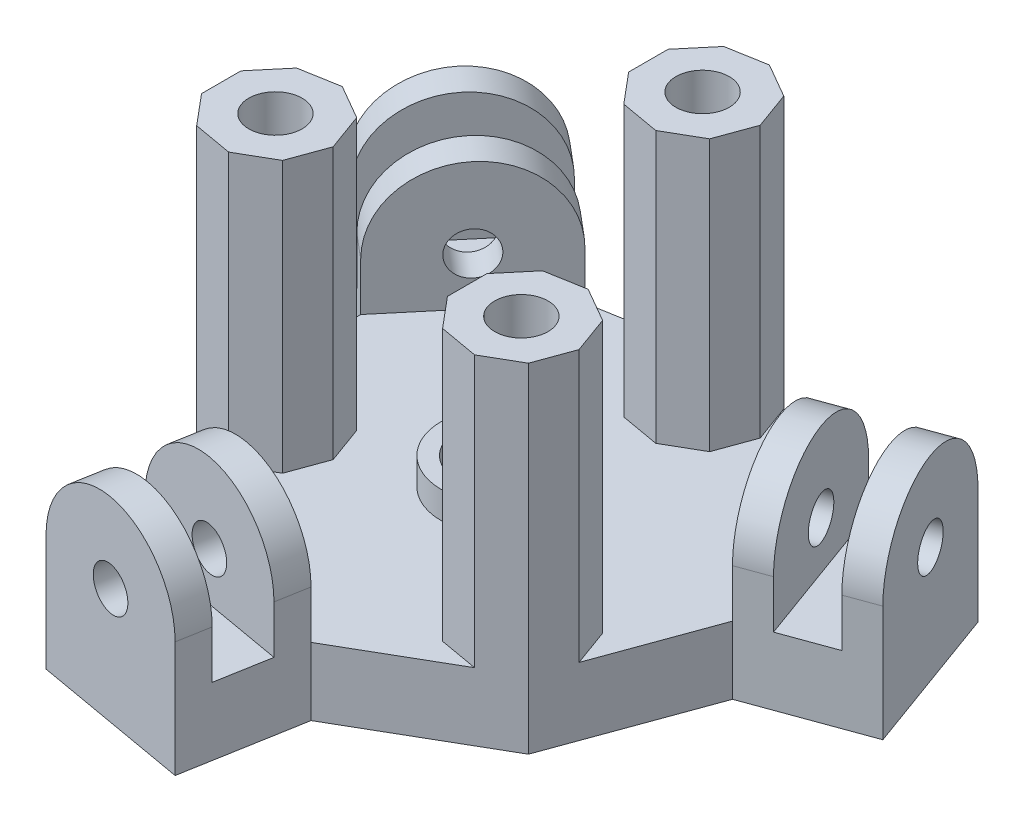
from build123d import *

# Parameters (mm, degrees)
SKETCH1_R            = 4.1
BOSS_EXTRUDE1_DEPTH  = 6.35
SKETCH4_R            = 2
BOSS_EXTRUDE2_DEPTH  = 3
SKETCH6_R            = 1.999996081
BOSS_EXTRUDE4_DEPTH  = 3
SKETCH8_R            = 1.999996
BOSS_EXTRUDE5_DEPTH  = 3
SKETCH9_R            = 1.999996
BOSS_EXTRUDE6_DEPTH  = 3
SKETCH10_R           = 1.999996
BOSS_EXTRUDE7_DEPTH  = 3
SKETCH11_R           = 1.999996
BOSS_EXTRUDE8_DEPTH  = 3
SKETCH12_R           = 2.5
BOSS_EXTRUDE9_DEPTH  = 25.4
SKETCH15_R           = 5.5
SKETCH15_R_2         = 4
BOSS_EXTRUDE10_DEPTH = 2.54


with BuildPart() as part:
    # Sketch1 → Boss-Extrude1 (new body)
    with BuildSketch(Plane(origin=(0, 0, 0), x_dir=(1, 0, 0), z_dir=(0, 1, 0))):
        Polygon((1.878116929, -32.317100962), (-12.817952122, -29.725787478), (-10.907822168, -18.892902195), (3.788246884, -21.484215679), align=None)
        Polygon((-10.907822168, -18.892902195), (3.788246884, -21.484215679), (16.711753116, -14.022825876), (21.815644336, 0), (16.711753116, 14.022825876), (3.788246884, 21.484215679), (-10.907822168, 18.892902195), (-20.5, 7.461389802), (-20.5, -7.461389802), align=None)
        Circle(SKETCH1_R, mode=Mode.SUBTRACT)
        Polygon((27.048371945, 17.785047453), (32.152263164, 3.762221577), (21.815644336, 0), (16.711753116, 14.022825876), align=None)
        Polygon((-28.926488874, 14.532053509), (-19.334311042, 25.963565901), (-10.907822168, 18.892902195), (-20.5, 7.461389802), align=None)
    extrude(amount=BOSS_EXTRUDE1_DEPTH)

    # Sketch4 → Boss-Extrude2 (add)
    with BuildSketch(Plane(origin=(-5.469917597, 0, 31.02144422), x_dir=(-0.984807753, 0, -0.173648178), z_dir=(0.173648178, 0, -0.984807753))):
        with BuildLine():
            Line((-7.461389802, 6.35), (-7.461389802, 10.84999989))
            ThreePointArc((-7.461389802, 10.84999989), (0, 18.311389692), (7.461389802, 10.84999989))
            Line((7.461389802, 10.84999989), (7.461389802, 6.35))
            Line((7.461389802, 6.35), (-7.461389802, 6.35))
        make_face()
        with Locations((0, 10.84999989)):
            Circle(SKETCH4_R, mode=Mode.SUBTRACT)
    extrude(amount=BOSS_EXTRUDE2_DEPTH)

    # Sketch6 → Boss-Extrude4 (add)
    with BuildSketch(Plane(origin=(-3.559787642, 0, 20.188558937), x_dir=(-0.984807753, 0, -0.173648178), z_dir=(0.173648178, 0, -0.984807753))):
        with BuildLine():
            Line((-7.461389802, 6.35), (-7.461389802, 10.85))
            ThreePointArc((-7.461389802, 10.85), (0, 18.311389802), (7.461389802, 10.85))
            Line((7.461389802, 10.85), (7.461389802, 6.35))
            Line((7.461389802, 6.35), (-7.461389802, 6.35))
        make_face()
        with Locations((0, 10.85)):
            Circle(SKETCH6_R, mode=Mode.SUBTRACT)
    extrude(amount=-BOSS_EXTRUDE4_DEPTH)

    # Sketch8 → Boss-Extrude5 (add)
    with BuildSketch(Plane(origin=(29.600317555, 0, -10.773634515), x_dir=(0.342020143, 0, 0.939692621), z_dir=(-0.939692621, 0, 0.342020143))):
        with BuildLine():
            Line((-7.461389802, 10.85), (-7.461389802, 6.35))
            Line((-7.461389802, 6.35), (7.461389802, 6.35))
            Line((7.461389802, 6.35), (7.461389802, 10.85))
            ThreePointArc((7.461389802, 10.85), (0, 18.311389802), (-7.461389802, 10.85))
        make_face()
        with Locations((0, 10.85)):
            Circle(SKETCH8_R, mode=Mode.SUBTRACT)
    extrude(amount=BOSS_EXTRUDE5_DEPTH)

    # Sketch9 → Boss-Extrude6 (add)
    with BuildSketch(Plane(origin=(19.263698726, 0, -7.011412938), x_dir=(0.342020143, 0, 0.939692621), z_dir=(-0.939692621, 0, 0.342020143))):
        with BuildLine():
            Line((-7.461389802, 6.35), (-7.461389802, 10.85))
            ThreePointArc((-7.461389802, 10.85), (0, 18.311389802), (7.461389802, 10.85))
            Line((7.461389802, 10.85), (7.461389802, 6.35))
            Line((7.461389802, 6.35), (-7.461389802, 6.35))
        make_face()
        with Locations((0, 10.85)):
            Circle(SKETCH9_R, mode=Mode.SUBTRACT)
    extrude(amount=-BOSS_EXTRUDE6_DEPTH)

    # Sketch10 → Boss-Extrude7 (add)
    with BuildSketch(Plane(origin=(-24.130399958, 0, -20.247809705), x_dir=(0.64278761, 0, -0.766044443), z_dir=(0.766044443, 0, 0.64278761))):
        with BuildLine():
            Line((-7.461389802, 10.85), (-7.461389802, 6.35))
            Line((-7.461389802, 6.35), (7.461389802, 6.35))
            Line((7.461389802, 6.35), (7.461389802, 10.85))
            ThreePointArc((7.461389802, 10.85), (0, 18.311389802), (-7.461389802, 10.85))
        make_face()
        with Locations((0, 10.85)):
            Circle(SKETCH10_R, mode=Mode.SUBTRACT)
    extrude(amount=BOSS_EXTRUDE7_DEPTH)

    # Sketch11 → Boss-Extrude8 (add)
    with BuildSketch(Plane(origin=(-15.703911084, 0, -13.177145999), x_dir=(0.64278761, 0, -0.766044443), z_dir=(0.766044443, 0, 0.64278761))):
        with BuildLine():
            Line((-7.461389802, 10.85), (-7.461389802, 6.35))
            Line((-7.461389802, 6.35), (7.461389802, 6.35))
            Line((7.461389802, 6.35), (7.461389802, 10.85))
            ThreePointArc((7.461389802, 10.85), (0, 18.311389802), (-7.461389802, 10.85))
        make_face()
        with Locations((0, 10.85)):
            Circle(SKETCH11_R, mode=Mode.SUBTRACT)
    extrude(amount=-BOSS_EXTRUDE8_DEPTH)

    # Sketch12 → Boss-Extrude9 (add)
    with BuildSketch(Plane(origin=(0, 6.35, 0), x_dir=(1, 0, 0), z_dir=(0, 1, 0))):
        Polygon((16.711753116, -14.022825876), (17.976522258, -10.54790122), (16.711753116, -7.072976564), (13.50924523, -5.224007774), (9.867487631, -5.866147896), (7.490499173, -8.69893243), (7.490499173, -12.39687001), (9.867487631, -15.229654545), (13.50924523, -15.871794666), align=None)
        with Locations((12.570499173, -10.54790122)):
            Circle(SKETCH12_R, mode=Mode.SUBTRACT)
        Polygon((6.99075477, 12.685397576), (8.255523911, 16.160322233), (6.99075477, 19.635246889), (3.788246884, 21.484215679), (0.146489284, 20.842075557), (-2.230499173, 18.009291023), (-2.230499173, 14.311353442), (0.146489284, 11.478568908), (3.788246884, 10.836428786), align=None)
        with Locations((2.849500827, 16.160322233)):
            Circle(SKETCH12_R, mode=Mode.SUBTRACT)
        Polygon((-20.5, -7.461389802), (-18.123011542, -10.294174337), (-14.481253943, -10.936314459), (-11.278746057, -9.087345669), (-10.013976916, -5.612421012), (-11.278746057, -2.137496356), (-14.481253943, -0.288527566), (-18.123011542, -0.930667688), (-20.5, -3.763452222), align=None)
        with Locations((-15.42, -5.612421012)):
            Circle(SKETCH12_R, mode=Mode.SUBTRACT)
    extrude(amount=BOSS_EXTRUDE9_DEPTH)

    # Sketch15 → Boss-Extrude10 (add)
    with BuildSketch(Plane(origin=(0, 6.35, 0), x_dir=(1, 0, 0), z_dir=(0, 1, 0))):
        Circle(SKETCH15_R)
        Circle(SKETCH15_R_2, mode=Mode.SUBTRACT)
    extrude(amount=BOSS_EXTRUDE10_DEPTH)


solid = part.part
